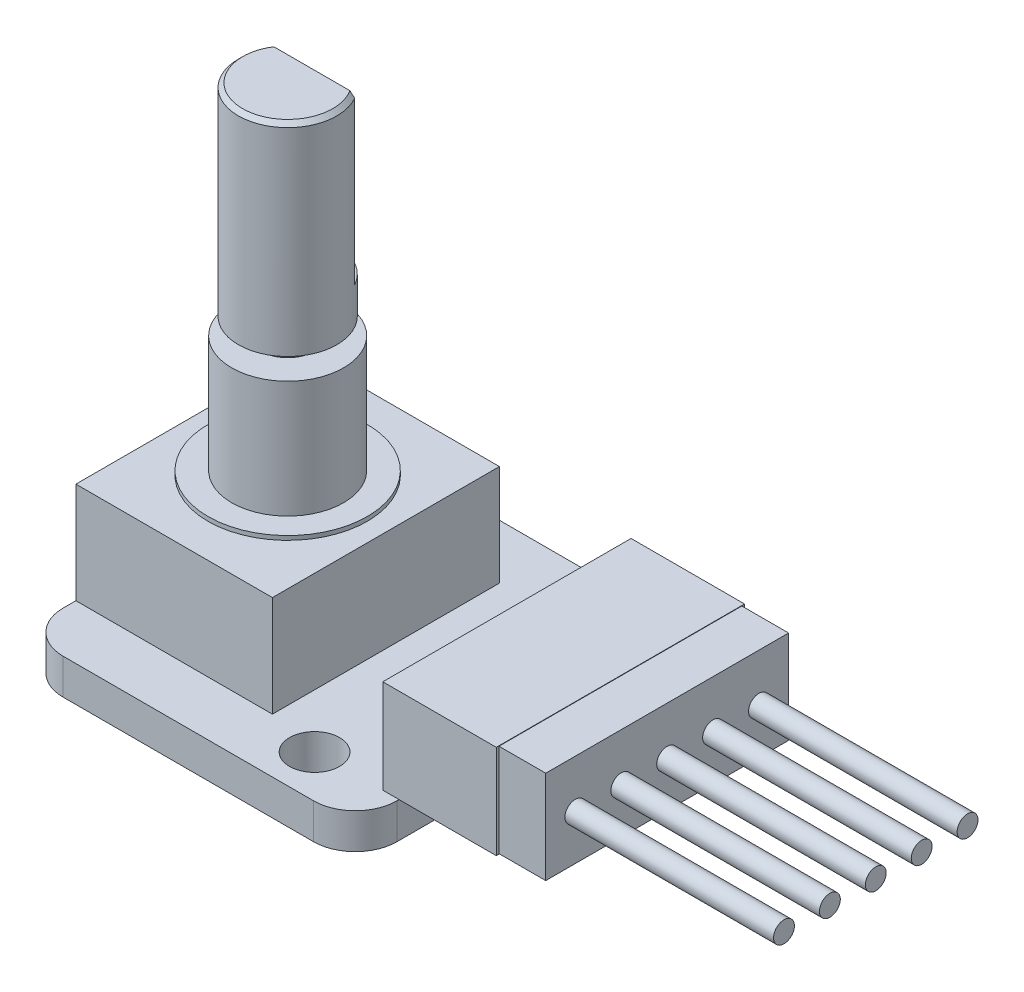
from build123d import *

# Parameters (mm, degrees)
SKETCH1_W           = 20.32
SKETCH1_H           = 20.447
BOSS_EXTRUDE1_DEPTH = 2.159
FILLET1_R           = 2.54
SKETCH2_W           = 6.9088
SKETCH2_H           = 15.113
BOSS_EXTRUDE2_DEPTH = 5.715
SKETCH3_W           = 11.9634
SKETCH3_H           = 13.8176
BOSS_EXTRUDE3_DEPTH = 6.1468
SKETCH4_R           = 4.8514
BOSS_EXTRUDE4_DEPTH = 0.254
SKETCH5_R           = 3.4036
BOSS_EXTRUDE5_DEPTH = 7.112
SKETCH6_R           = 1.651
BOSS_EXTRUDE6_DEPTH = 1.016
SKETCH7_R           = 2.9972
BOSS_EXTRUDE7_DEPTH = 12.319
CUT_EXTRUDE1_DEPTH  = 10.0838
SKETCH9_W           = 14.7828
SKETCH9_H           = 5.6642
BOSS_EXTRUDE8_DEPTH = 2.8448
SKETCH10_R          = 0.635
BOSS_EXTRUDE9_DEPTH = 12.7
SKETCH11_R          = 1.524
CUT_EXTRUDE2_DEPTH  = 12.7
CHAMFER1_SIZE       = 0.254


with BuildPart() as part:
    # Sketch1 → Boss-Extrude1 (new body)
    with BuildSketch(Plane(origin=(0, 0, 0), x_dir=(1, 0, 0), z_dir=(0, 1, 0))):
        Rectangle(SKETCH1_W, SKETCH1_H)
    extrude(amount=BOSS_EXTRUDE1_DEPTH)

    # Fillet1
    fillet1_edges = [part.edges().sort_by_distance(p)[0] for p in [
        (-10.16, 1.0795, -10.2235),
        (10.16, 1.0795, -10.2235),
        (10.16, 1.0795, 10.2235),
        (-10.16, 1.0795, 10.2235),
    ]]
    fillet(fillet1_edges, radius=FILLET1_R)

    # Sketch2 → Boss-Extrude2 (add)
    with BuildSketch(Plane(origin=(0, 2.159, 0), x_dir=(1, 0, 0), z_dir=(0, 1, 0))):
        with Locations((12.6238, 0)):
            Rectangle(SKETCH2_W, SKETCH2_H)
    extrude(amount=BOSS_EXTRUDE2_DEPTH)

    # Sketch3 → Boss-Extrude3 (add)
    with BuildSketch(Plane(origin=(0, 2.159, 0), x_dir=(1, 0, 0), z_dir=(0, 1, 0))):
        with Locations((-4.1783, 0)):
            Rectangle(SKETCH3_W, SKETCH3_H)
    extrude(amount=BOSS_EXTRUDE3_DEPTH)

    # Sketch4 → Boss-Extrude4 (add)
    with BuildSketch(Plane(origin=(0, 8.3058, 0), x_dir=(1, 0, 0), z_dir=(0, 1, 0))):
        with Locations((-4.1783, 0)):
            Circle(SKETCH4_R)
    extrude(amount=BOSS_EXTRUDE4_DEPTH)

    # Sketch5 → Boss-Extrude5 (add)
    with BuildSketch(Plane(origin=(0, 8.5598, 0), x_dir=(1, 0, 0), z_dir=(0, 1, 0))):
        with Locations((-4.1783, 0)):
            Circle(SKETCH5_R)
    extrude(amount=BOSS_EXTRUDE5_DEPTH)

    # Sketch6 → Boss-Extrude6 (add)
    with BuildSketch(Plane(origin=(0, 15.6718, 0), x_dir=(1, 0, 0), z_dir=(0, 1, 0))):
        with Locations((-4.1783, 0)):
            Circle(SKETCH6_R)
    extrude(amount=BOSS_EXTRUDE6_DEPTH)

    # Sketch7 → Boss-Extrude7 (add)
    with BuildSketch(Plane(origin=(0, 16.6878, 0), x_dir=(1, 0, 0), z_dir=(0, 1, 0))):
        with Locations((-4.1783, 0)):
            Circle(SKETCH7_R)
    extrude(amount=BOSS_EXTRUDE7_DEPTH)

    # Sketch8 → Cut-Extrude1 (cut)
    with BuildSketch(Plane(origin=(0, 29.0068, 0), x_dir=(1, 0, 0), z_dir=(0, 1, 0))):
        with BuildLine():
            Line((-6.78845126, 1.4732), (-1.56814874, 1.4732))
            ThreePointArc((-1.56814874, 1.4732), (-4.1783, 2.9972), (-6.78845126, 1.4732))
        make_face()
    extrude(amount=-CUT_EXTRUDE1_DEPTH, mode=Mode.SUBTRACT)

    # Sketch9 → Boss-Extrude8 (add)
    with BuildSketch(Plane(origin=(16.0782, 0, 0), x_dir=(0, 0, -1), z_dir=(1, 0, 0))):
        with Locations((0, 5.0165)):
            Rectangle(SKETCH9_W, SKETCH9_H)
    extrude(amount=BOSS_EXTRUDE8_DEPTH)

    # Sketch10 → Boss-Extrude9 (add)
    with BuildSketch(Plane(origin=(18.923, 0, 0), x_dir=(0, 0, -1), z_dir=(1, 0, 0))):
        with Locations((0, 4.935778059)):
            Circle(SKETCH10_R)
        with Locations((2.794, 4.935778059)):
            Circle(SKETCH10_R)
        with Locations((5.588, 4.935778059)):
            Circle(SKETCH10_R)
        with Locations((-2.794, 4.935778059)):
            Circle(SKETCH10_R)
        with Locations((-5.588, 4.935778059)):
            Circle(SKETCH10_R)
    extrude(amount=BOSS_EXTRUDE9_DEPTH)

    # Sketch11 → Cut-Extrude2 (cut)
    with BuildSketch(Plane(origin=(0, 2.159, 0), x_dir=(1, 0, 0), z_dir=(0, 1, 0))):
        with Locations((5.08, 7.62)):
            Circle(SKETCH11_R)
        with Locations((5.08, -7.62)):
            Circle(SKETCH11_R)
    extrude(amount=-CUT_EXTRUDE2_DEPTH, mode=Mode.SUBTRACT)

    # Chamfer1
    chamfer1_edges = [part.edges().sort_by_distance(p)[0] for p in [
        (-4.939897822, 29.0068, 2.898823313),
    ]]
    chamfer(chamfer1_edges, length=CHAMFER1_SIZE)


solid = part.part
